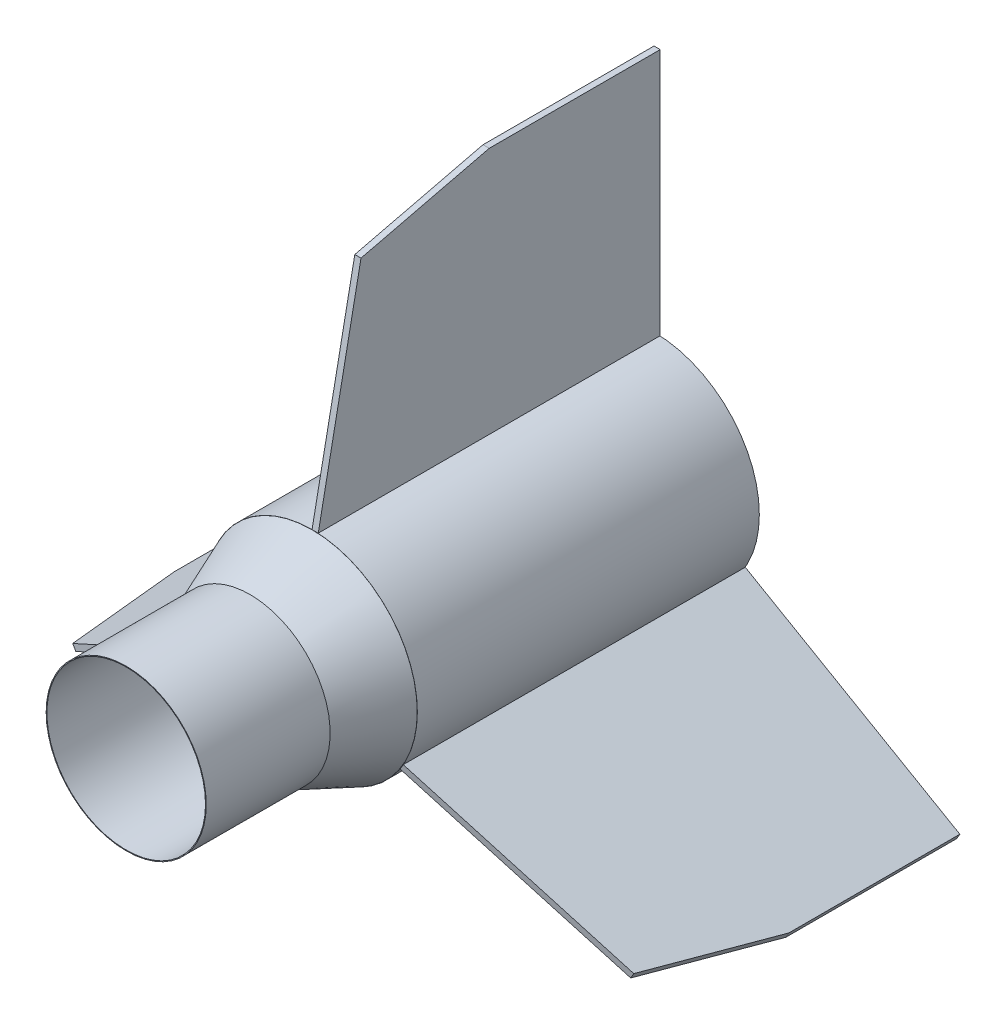
from build123d import *

# Parameters (mm, degrees)
SKETCH1_R           = 21.59
SKETCH1_R_2         = 9.144
BOSS_EXTRUDE1_DEPTH = 70.1
SKETCH2_R           = 16.4084
SKETCH2_R_2         = 16.256
BOSS_EXTRUDE2_DEPTH = 38.1
BOSS_EXTRUDE6_DEPTH = 1.27
CIRPATTERN7_COUNT   = 3


with BuildPart() as part:
    # Sketch1 → Boss-Extrude1 (new body)
    with BuildSketch(Plane.XY):
        Circle(SKETCH1_R)
        with Locations((0.118855304, -11.557)):
            Circle(SKETCH1_R_2, mode=Mode.SUBTRACT)
        with Locations((9.955579479, 5.869470694)):
            Circle(SKETCH1_R_2, mode=Mode.SUBTRACT)
        with Locations((-10.060900468, 5.687049391)):
            Circle(SKETCH1_R_2, mode=Mode.SUBTRACT)
    extrude(amount=BOSS_EXTRUDE1_DEPTH)

    # Sketch2 → Boss-Extrude2 (add)
    with BuildSketch(Plane.XY.offset(70.1)):
        Circle(SKETCH2_R)
        Circle(SKETCH2_R_2, mode=Mode.SUBTRACT)
    extrude(amount=BOSS_EXTRUDE2_DEPTH)

    # Sketch8 → Revolve3 (revolve)
    with BuildSketch(Plane(origin=(0, 0, 0), x_dir=(0, 0, -1), z_dir=(1, 0, 0))):
        Polygon((-70.1, 21.56234654), (-82.8, 16.4084), (-70.1, 16.4084), align=None)
    revolve(axis=Axis((0, 0, 126.159811209), (0, 0, -1)))


with BuildPart() as body_2:
    # Sketch14 → Boss-Extrude6 (new body)
    with BuildSketch(Plane(origin=(0, 0, 0), x_dir=(0, 0, -1), z_dir=(1, 0, 0))):
        Polygon((-70.1, 21.59), (-61.3375, 66.04), (-35.05, 72.39), (0, 72.39), (0, 46.99), (0, 21.59), align=None)
    extrude(amount=BOSS_EXTRUDE6_DEPTH)


with BuildPart() as cirpattern7_1:
    # CirPattern7: pattern copy
    add(body_2.part.rotate(Axis((0, 0, 0), (0, 0, 1)), 1 * 360 / CIRPATTERN7_COUNT))


with BuildPart() as cirpattern7_2:
    # CirPattern7: pattern copy
    add(body_2.part.rotate(Axis((0, 0, 0), (0, 0, 1)), 2 * 360 / CIRPATTERN7_COUNT))


solid = Compound([part.part, body_2.part, cirpattern7_1.part, cirpattern7_2.part])
